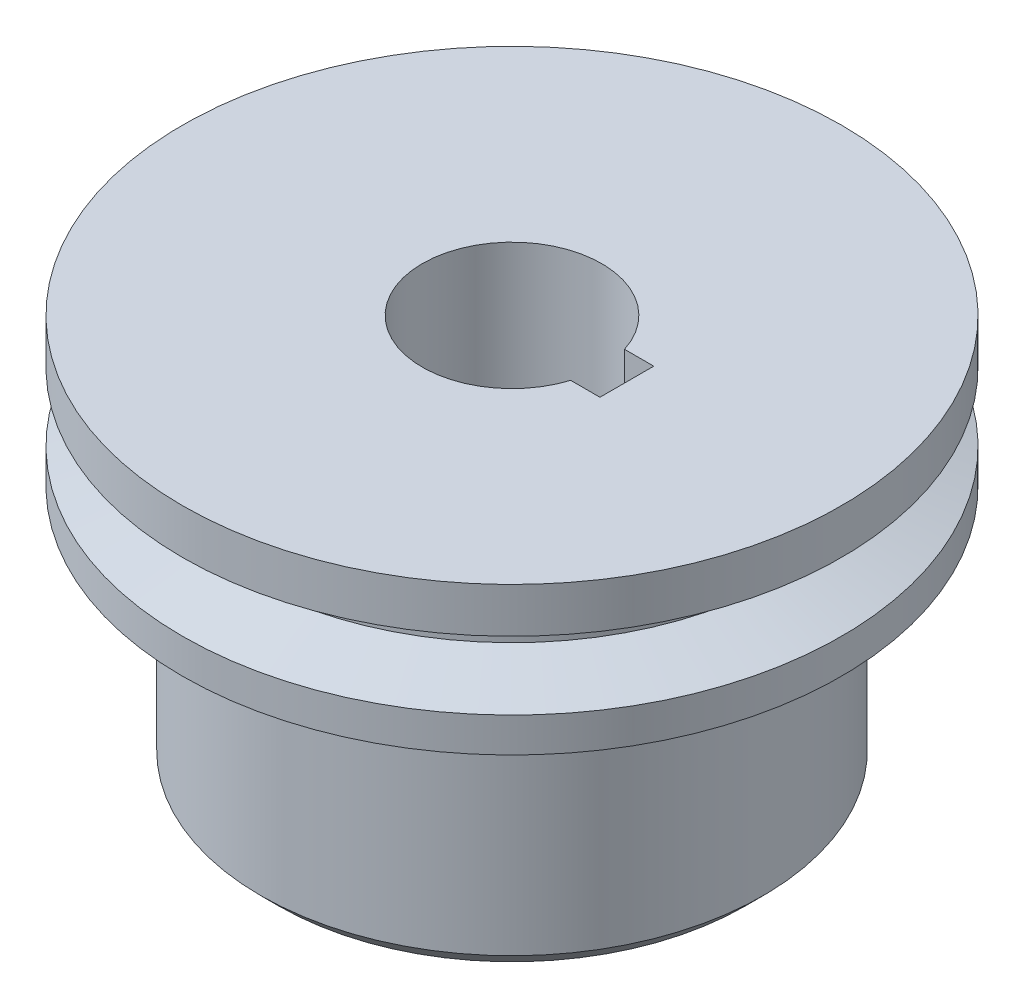
from build123d import *

# Parameters (mm, degrees)
SKETCH1_R           = 14
BOSS_EXTRUDE2_DEPTH = 22
CHAMFER1_SIZE       = 1


with BuildPart() as part:
    # Sketch1 → Boss-Extrude2 (new body)
    with BuildSketch(Plane(origin=(0, 0, 0), x_dir=(1, 0, 0), z_dir=(0, 1, 0))):
        Circle(SKETCH1_R)
        with BuildLine():
            Line((4.769696007, -1.5), (6.4, -1.5))
            Line((6.4, -1.5), (6.4, 1.5))
            Line((6.4, 1.5), (4.769696007, 1.5))
            ThreePointArc((4.769696007, 1.5), (-5, 0), (4.769696007, -1.5))
        make_face(mode=Mode.SUBTRACT)
    extrude(amount=BOSS_EXTRUDE2_DEPTH)

    # Chamfer1
    chamfer1_edges = [part.edges().sort_by_distance(p)[0] for p in [
        (-14, 0, 0),
    ]]
    chamfer(chamfer1_edges, length=CHAMFER1_SIZE)

    # Sketch2 → Revolve1 (revolve)
    with BuildSketch(Plane(origin=(0, 0, 0), x_dir=(0, 0, -1), z_dir=(1, 0, 0))):
        Polygon((14, 22), (18.362757193, 22), (18.362757193, 19.5), (15, 18.654420503), (15, 16.811960425), (18.362757193, 15.697914797), (18.362757193, 13.769758902), (14, 13.769758902), align=None)
    revolve(axis=Axis((0, 22, 0), (0, -1, 0)))


solid = part.part
